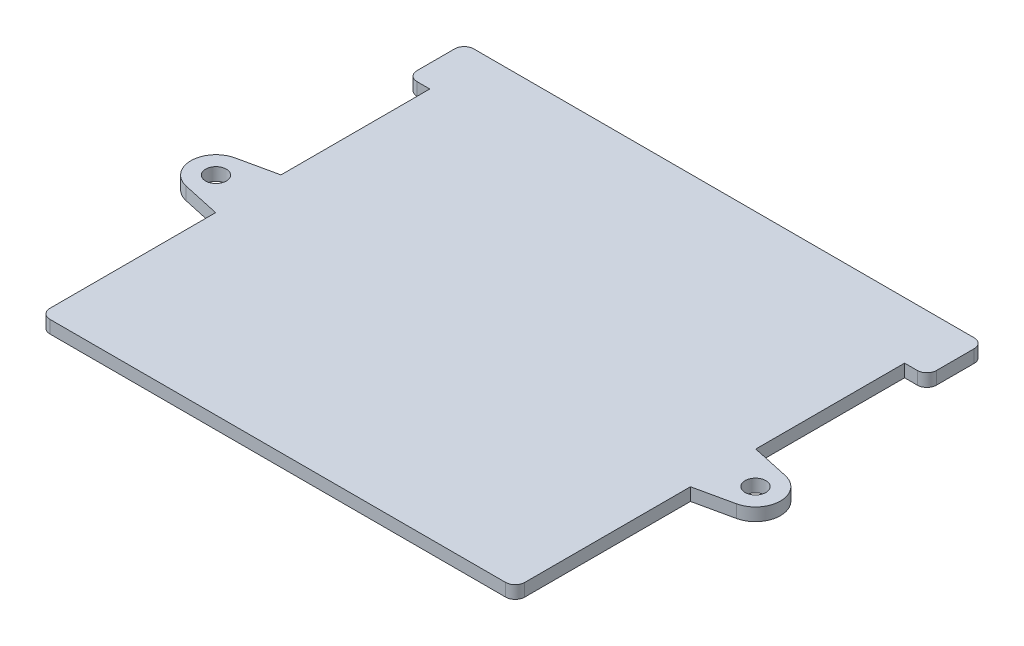
from build123d import *

# Parameters (mm, degrees)
SKETCH1_R           = 3.25
BOSS_EXTRUDE1_DEPTH = 4
FILLET7_R           = 3


with BuildPart() as part:
    # Sketch1 → Boss-Extrude1 (new body)
    with BuildSketch(Plane(origin=(0, 0, 0), x_dir=(1, 0, 0), z_dir=(0, 1, 0))):
        with BuildLine():
            Line((74.5, 0), (-74.5, 0))
            Line((-74.5, 0), (-74.5, 55))
            Line((-74.5, 55), (-86.323846824, 57.580532169))
            ThreePointArc((-86.323846824, 57.580532169), (-92.5, 65.25), (-86.323846824, 72.919467831))
            Line((-86.323846824, 72.919467831), (-74.5, 75.5))
            Line((-74.5, 75.5), (-74.5, 122.2))
            Line((-74.5, 122.2), (-81.5, 122.2))
            Line((-81.5, 122.2), (-81.5, 140))
            Line((-81.5, 140), (81.5, 140))
            Line((81.5, 140), (81.5, 122.2))
            Line((81.5, 122.2), (74.5, 122.2))
            Line((74.5, 122.2), (74.5, 75.5))
            Line((74.5, 75.5), (86.323846824, 72.919467831))
            ThreePointArc((86.323846824, 72.919467831), (92.5, 65.25), (86.323846824, 57.580532169))
            Line((86.323846824, 57.580532169), (74.5, 55))
            Line((74.5, 55), (74.5, 0))
        make_face()
        with Locations((-84.65, 65.25)):
            Circle(SKETCH1_R, mode=Mode.SUBTRACT)
        with Locations((84.65, 65.25)):
            Circle(SKETCH1_R, mode=Mode.SUBTRACT)
    extrude(amount=BOSS_EXTRUDE1_DEPTH)

    # Fillet7
    fillet7_edges = [part.edges().sort_by_distance(p)[0] for p in [
        (74.5, 2, 0),
        (-74.5, 2, 0),
        (-81.5, 2, -122.2),
        (-81.5, 2, -140),
        (81.5, 2, -140),
        (81.5, 2, -122.2),
    ]]
    fillet(fillet7_edges, radius=FILLET7_R)


solid = part.part
